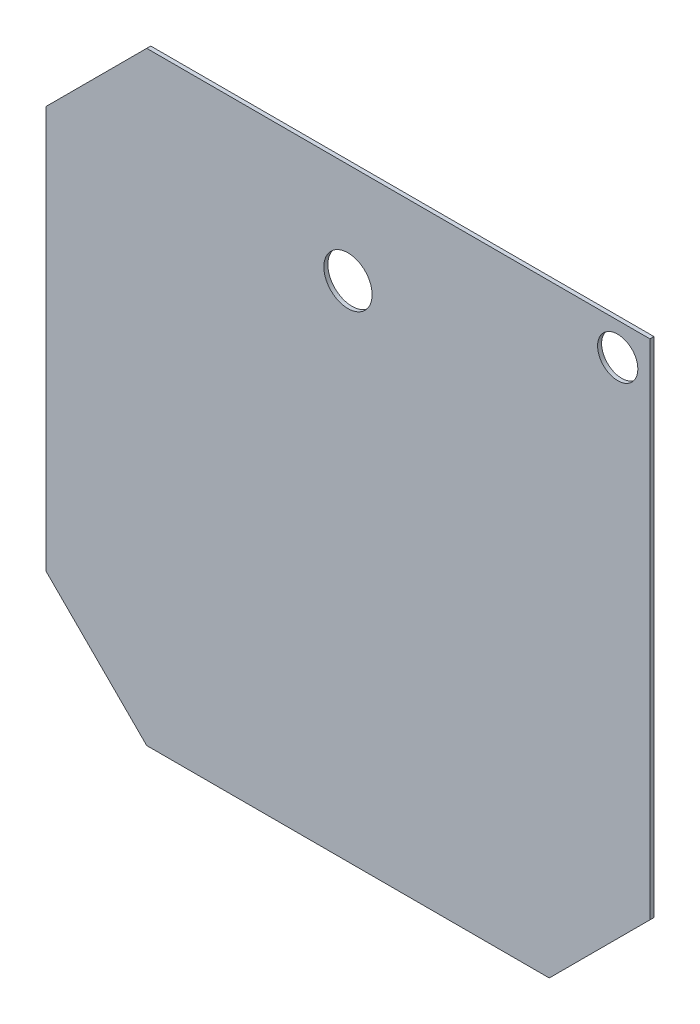
from build123d import *

# Parameters (mm, degrees)
SKETCH1_R           = 6
BOSS_EXTRUDE1_DEPTH = 1
SKETCH2_R           = 5
CUT_EXTRUDE1_DEPTH  = 10


with BuildPart() as part:
    # Sketch1 → Boss-Extrude1 (new body)
    with BuildSketch(Plane.XY):
        Polygon((-75, 50), (-50, 75), (75, 75), (75, -50), (50, -75), (-50, -75), (-75, -50), align=None)
        with Locations((0, 50)):
            Circle(SKETCH1_R, mode=Mode.SUBTRACT)
    extrude(amount=BOSS_EXTRUDE1_DEPTH)

    # Sketch2 → Cut-Extrude1 (cut)
    with BuildSketch(Plane.XY.offset(1)):
        with Locations((67, 67)):
            Circle(SKETCH2_R)
    extrude(amount=-CUT_EXTRUDE1_DEPTH, mode=Mode.SUBTRACT)


solid = part.part
